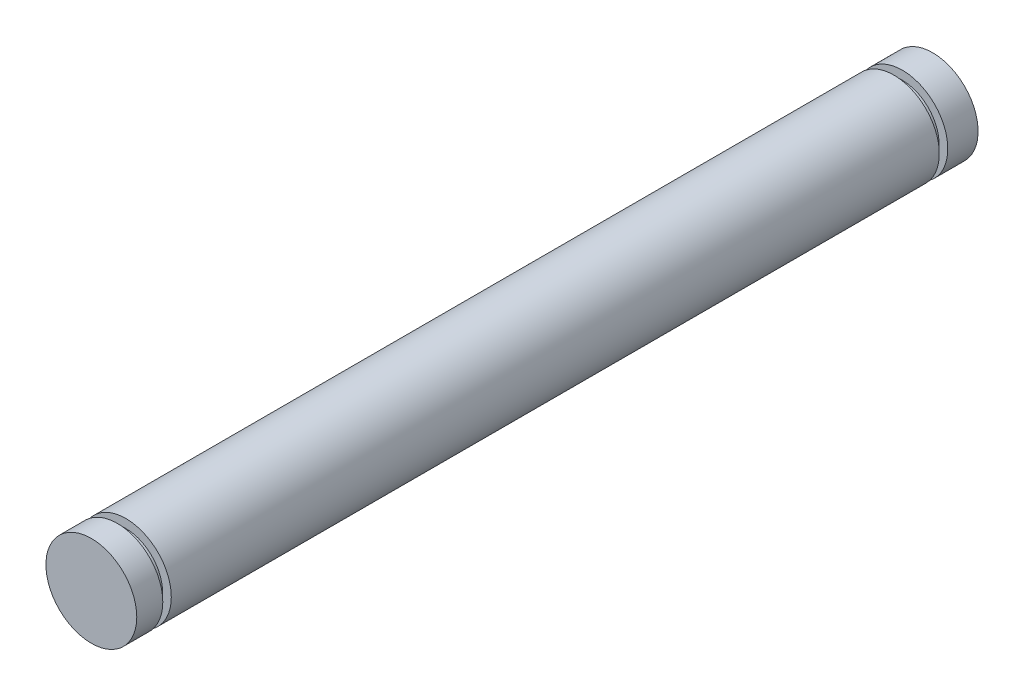
from build123d import *

# Parameters (mm, degrees)
SKETCH1_R           = 4.7625
BOSS_EXTRUDE1_DEPTH = 97.3074
SKETCH3_R           = 9.078890277
SKETCH3_R_2         = 3.8481
CUT_EXTRUDE1_DEPTH  = 0.4445
SKETCH4_R           = 7.766517843
SKETCH4_R_2         = 3.8481
CUT_EXTRUDE2_DEPTH  = 0.4445
SKETCH5_R           = 6.35
CUT_EXTRUDE3_DEPTH  = 5.5118
SKETCH6_R           = 6.35
CUT_EXTRUDE4_DEPTH  = 3.5941


with BuildPart() as part:
    # Sketch1 → Boss-Extrude1 (new body)
    with BuildSketch(Plane.XY):
        Circle(SKETCH1_R)
    extrude(amount=BOSS_EXTRUDE1_DEPTH)

    # Sketch3 → Cut-Extrude1 (cut, symmetric)
    with BuildSketch(Plane(origin=(0, 0, 7.2136), x_dir=(-1, 0, 0), z_dir=(0, 0, -1))):
        Circle(SKETCH3_R)
        Circle(SKETCH3_R_2, mode=Mode.SUBTRACT)
    extrude(amount=CUT_EXTRUDE1_DEPTH, both=True, mode=Mode.SUBTRACT)

    # Sketch4 → Cut-Extrude2 (cut, symmetric)
    with BuildSketch(Plane.XY.offset(88.6206)):
        Circle(SKETCH4_R)
        Circle(SKETCH4_R_2, mode=Mode.SUBTRACT)
    extrude(amount=CUT_EXTRUDE2_DEPTH, both=True, mode=Mode.SUBTRACT)

    # Sketch5 → Cut-Extrude3 (cut)
    with BuildSketch(Plane.XY.offset(97.3074)):
        Circle(SKETCH5_R)
    extrude(amount=-CUT_EXTRUDE3_DEPTH, mode=Mode.SUBTRACT)

    # Sketch6 → Cut-Extrude4 (cut)
    with BuildSketch(Plane(origin=(0, 0, 0), x_dir=(-1, 0, 0), z_dir=(0, 0, -1))):
        Circle(SKETCH6_R)
    extrude(amount=-CUT_EXTRUDE4_DEPTH, mode=Mode.SUBTRACT)


solid = part.part
